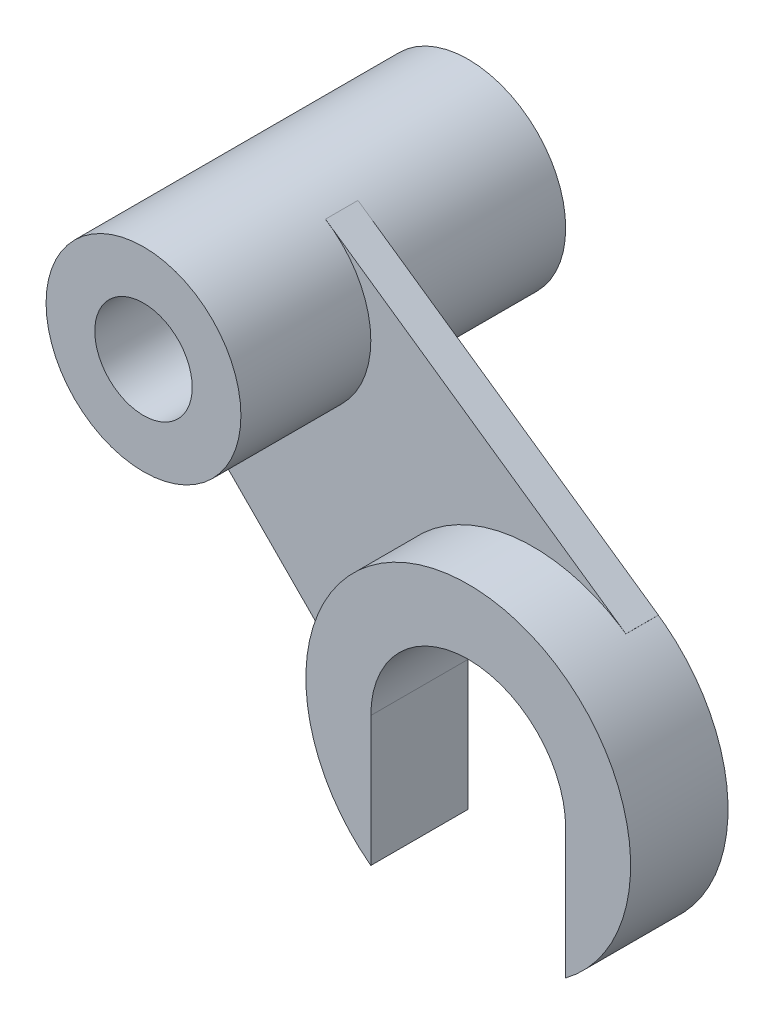
from build123d import *

# Parameters (mm, degrees)
BOSS_EXTRUDE1_DEPTH = 30
SKETCH1_3_R         = 30
BOSS_EXTRUDE2_DEPTH = 50
SKETCH1_4_R         = 15
CUT_EXTRUDE1_DEPTH  = 50
BOSS_EXTRUDE4_DEPTH = 10


with BuildPart() as part:
    # Sketch1 → Boss-Extrude1 (new body)
    with BuildSketch(Plane.XY):
        with BuildLine():
            Line((-30, 0), (-30, -40))
            ThreePointArc((-30, -40), (0, 50), (30, -40))
            Line((30, -40), (30, 0))
            ThreePointArc((30, 0), (0, 30), (-30, 0))
        make_face()
    extrude(amount=BOSS_EXTRUDE1_DEPTH)


with BuildPart() as body_2:
    # Sketch1_3 → Boss-Extrude2 (new, symmetric)
    with BuildSketch(Plane.XY):
        with Locations((-80, 80)):
            Circle(SKETCH1_3_R)
    extrude(amount=BOSS_EXTRUDE2_DEPTH, both=True)

    # Sketch1_4 → Cut-Extrude1 (cut, symmetric)
    with BuildSketch(Plane.XY):
        with Locations((-80, 80)):
            Circle(SKETCH1_4_R)
    extrude(amount=CUT_EXTRUDE1_DEPTH, both=True, mode=Mode.SUBTRACT)


with BuildPart() as body_3:
    # Sketch2 → Boss-Extrude4 (new body)
    with BuildSketch(Plane.XY):
        Polygon((-110, 80), (-110, 40), (-35.522635393, -35.187247331), (-35.522635393, 24.424406647), (0, 40), (24.418101719, 32.212203323), (28.548527268, 41.048527268), (-63.960088523, 105.386639161), (-57.46096906, 69.201073422), (-82.980642429, 54.816403079), (-101.405140795, 67.630316976), align=None)
    extrude(amount=BOSS_EXTRUDE4_DEPTH)


solid = Compound([part.part, body_2.part, body_3.part])
